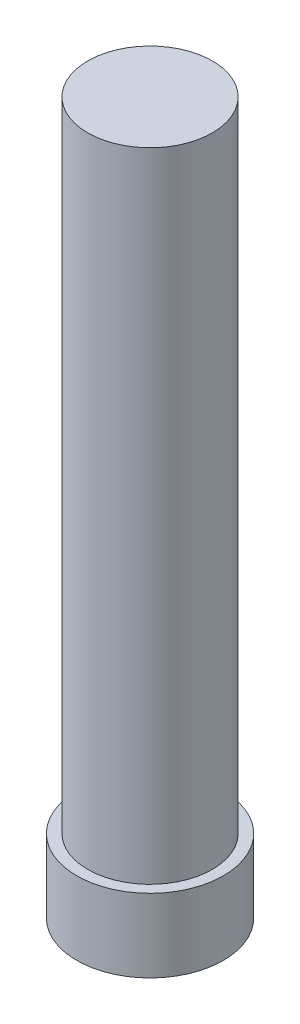
from build123d import *

# Parameters (mm, degrees)
SKETCH_2_R      = 0.85
EXTRUDE_1_DEPTH = 8.7
SKETCH_3_R      = 1
EXTRUDE_2_DEPTH = 1


with BuildPart() as part:
    # 草图2 → 凸台-拉伸1 (new body)
    with BuildSketch(Plane(origin=(0, 0, 0), x_dir=(1, 0, 0), z_dir=(0, 1, 0))):
        Circle(SKETCH_2_R)
    extrude(amount=EXTRUDE_1_DEPTH)

    # 草图3 → 凸台-拉伸2 (add)
    with BuildSketch(Plane.XZ):
        Circle(SKETCH_3_R)
    extrude(amount=EXTRUDE_2_DEPTH)


solid = part.part
